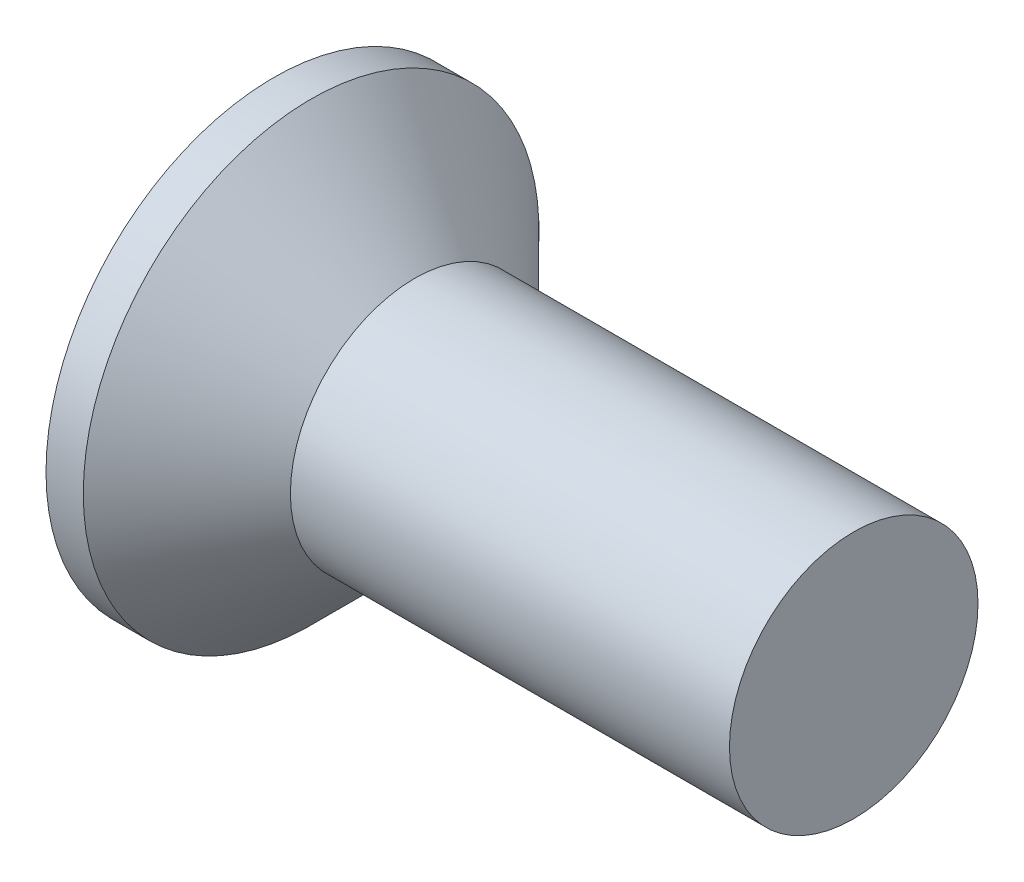
from build123d import *

# Parameters (mm, degrees)
SKETCH3_W         = 0.79
SKETCH3_H         = 3.1
SKETCH4_W         = 0.395
SKETCH4_H         = 0.395
CIRPATTERN1_COUNT = 2
CIRPATTERN1_ANGLE = 90


with BuildPart() as part:
    # BodySke → Base-Revolve (revolve)
    with BuildSketch(Plane.XY, mode=Mode.PRIVATE) as base_revolve_sk:
        Polygon((0, 0), (0, 2.75), (0.45, 2.75), (1.7, 1.5), (7, 1.5), (7, 0), align=None)
    revolve(base_revolve_sk.sketch.rotate(Axis((-6.35, 0, 0), (1, 0, 0)), 90), axis=Axis((-6.35, 0, 0), (1, 0, 0)))  # turned: the seam where the file's is

    # Sketch3 → Cross section 0
    with BuildSketch(Plane.ZY):
        Rectangle(SKETCH3_W, SKETCH3_H)
    # Sketch4 → Cross section 1
    with BuildSketch(Plane.ZY.offset(-2.08)):
        Rectangle(SKETCH4_W, SKETCH4_H)
    cross = loft(mode=Mode.SUBTRACT)

    # CirPattern1: Cross ×2 about axis
    cirpattern1_axis = Axis((0, 0, 0), (1, 0, 0))
    for i in range(1, CIRPATTERN1_COUNT):
        add(cross.rotate(cirpattern1_axis, i * CIRPATTERN1_ANGLE / (CIRPATTERN1_COUNT - 1)), mode=Mode.SUBTRACT)


solid = part.part
